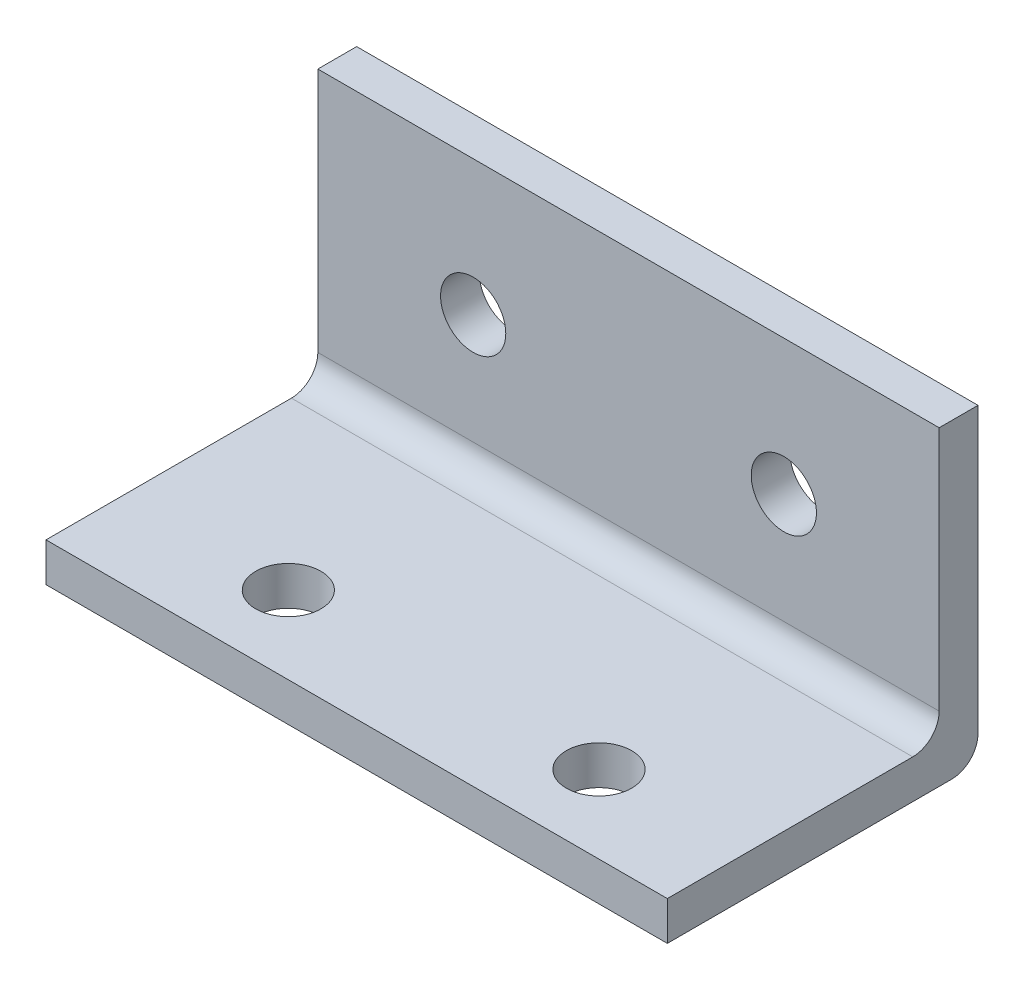
from build123d import *

# Parameters (mm, degrees)
BOSS_EXTRUDE1_DEPTH = 50.8
SKETCH2_R           = 2.667
CUT_EXTRUDE1_DEPTH  = 3.175
SKETCH3_R           = 2.667
CUT_EXTRUDE2_DEPTH  = 3.175
FILLET1_R           = 2.159


with BuildPart() as part:
    # Sketch1 → Boss-Extrude1 (new body)
    with BuildSketch(Plane(origin=(0, 0, 0), x_dir=(0, 0, -1), z_dir=(1, 0, 0))):
        Polygon((0, 0), (0, 25.4), (-3.175, 25.4), (-3.175, 3.175), (-25.4, 3.175), (-25.4, 0), align=None)
    extrude(amount=BOSS_EXTRUDE1_DEPTH)

    # Sketch2 → Cut-Extrude1 (cut)
    with BuildSketch(Plane(origin=(0, 3.175, 0), x_dir=(1, 0, 0), z_dir=(0, 1, 0))):
        with Locations((13.462, -19.05)):
            Circle(SKETCH2_R)
        with Locations((38.862, -19.05)):
            Circle(SKETCH2_R)
    extrude(amount=-CUT_EXTRUDE1_DEPTH, mode=Mode.SUBTRACT)

    # Sketch3 → Cut-Extrude2 (cut)
    with BuildSketch(Plane.XY.offset(3.175)):
        with Locations((38.1, 14.351)):
            Circle(SKETCH3_R)
        with Locations((12.7, 14.351)):
            Circle(SKETCH3_R)
    extrude(amount=-CUT_EXTRUDE2_DEPTH, mode=Mode.SUBTRACT)

    # Fillet1
    fillet1_edges = [part.edges().sort_by_distance(p)[0] for p in [
        (25.4, 3.175, 3.175),
        (25.4, 0, 0),
    ]]
    fillet(fillet1_edges, radius=FILLET1_R)


solid = part.part
